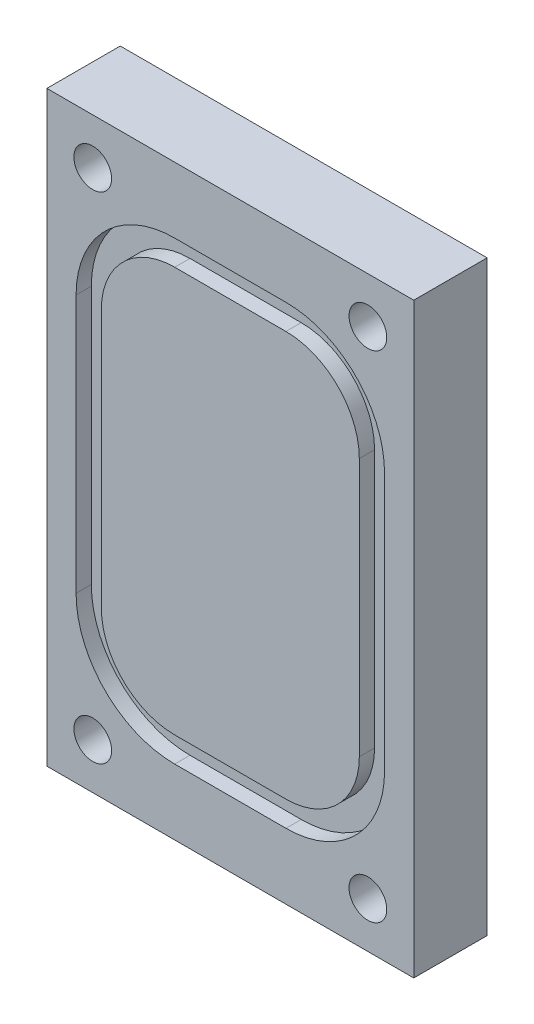
from build123d import *

# Parameters (mm, degrees)
SKETCH1_W                                         = 31.75
SKETCH1_H                                         = 50.8
BOSS_EXTRUDE1_DEPTH                               = 6.35
CUT_EXTRUDE2_DASH_027_DEPTH                       = 1.3208
CSK_FOR_4_FLAT_HEAD_MACHINE_SCREW_100_D           = 3.2639
CSK_FOR_4_FLAT_HEAD_MACHINE_SCREW_100_CSINK_D     = 5.715
CSK_FOR_4_FLAT_HEAD_MACHINE_SCREW_100_CSINK_ANGLE = 100


with BuildPart() as part:
    # Sketch1 → Boss-Extrude1 (new body)
    with BuildSketch(Plane.XY):
        Rectangle(SKETCH1_W, SKETCH1_H)
    extrude(amount=BOSS_EXTRUDE1_DEPTH)

    # Sketch3 → Cut-Extrude2 - dash 027 (cut)
    with BuildSketch(Plane.XY.offset(6.35)):
        with BuildLine():
            Line((13.3477, -11.176), (13.3477, 11.176))
            ThreePointArc((13.3477, 11.176), (10.848032113, 17.210732113), (4.8133, 19.7104))
            Line((4.8133, 19.7104), (-4.8133, 19.7104))
            ThreePointArc((-4.8133, 19.7104), (-10.848032113, 17.210732113), (-13.3477, 11.176))
            Line((-13.3477, 11.176), (-13.3477, -11.176))
            ThreePointArc((-13.3477, -11.176), (-10.848032113, -17.210732113), (-4.8133, -19.7104))
            Line((-4.8133, -19.7104), (4.8133, -19.7104))
            ThreePointArc((4.8133, -19.7104), (10.848032113, -17.210732113), (13.3477, -11.176))
        make_face()
        with BuildLine():
            Line((-4.8133, -17.526), (4.8133, -17.526))
            ThreePointArc((4.8133, -17.526), (9.303428061, -15.666128061), (11.1633, -11.176))
            Line((11.1633, -11.176), (11.1633, 11.176))
            ThreePointArc((11.1633, 11.176), (9.303428061, 15.666128061), (4.8133, 17.526))
            Line((4.8133, 17.526), (-4.8133, 17.526))
            ThreePointArc((-4.8133, 17.526), (-9.303428061, 15.666128061), (-11.1633, 11.176))
            Line((-11.1633, 11.176), (-11.1633, -11.176))
            ThreePointArc((-11.1633, -11.176), (-9.303428061, -15.666128061), (-4.8133, -17.526))
        make_face(mode=Mode.SUBTRACT)
    extrude(amount=-CUT_EXTRUDE2_DASH_027_DEPTH, mode=Mode.SUBTRACT)

    # CSK for #4 Flat Head Machine Screw (100)1 (through all)
    with Locations(Plane(origin=(0, 0, 0), x_dir=(-1, 0, 0), z_dir=(0, 0, -1))):
        with Locations((-11.90625, 21.43125), (11.90625, 21.43125), (-11.90625, -21.43125), (11.90625, -21.43125)):
            CounterSinkHole(CSK_FOR_4_FLAT_HEAD_MACHINE_SCREW_100_D / 2, CSK_FOR_4_FLAT_HEAD_MACHINE_SCREW_100_CSINK_D / 2, counter_sink_angle=CSK_FOR_4_FLAT_HEAD_MACHINE_SCREW_100_CSINK_ANGLE)


solid = part.part
